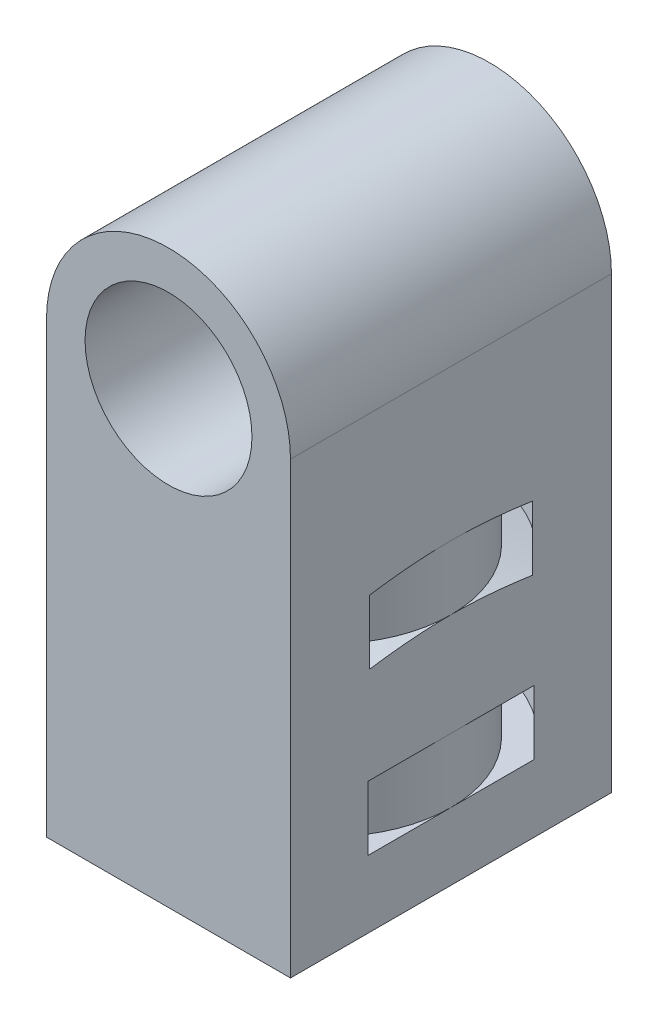
from build123d import *

# Parameters (mm, degrees)
CROQUIS1_R              = 6.5
SALIENTE_EXTRUIR1_DEPTH = 12.5
CROQUIS3_W              = 19
CROQUIS3_H              = 25
CROQUIS3_R              = 6.5
SALIENTE_EXTRUIR2_DEPTH = 25
CROQUIS8_W              = 2
CROQUIS8_H              = 5


with BuildPart() as part:
    # Croquis1 → Saliente-Extruir1 (new body, symmetric)
    with BuildSketch(Plane.XY):
        with BuildLine():
            Line((-9.5, -10), (9.5, -10))
            Line((9.5, -10), (9.5, 0))
            ThreePointArc((9.5, 0), (0, 9.5), (-9.5, 0))
            Line((-9.5, 0), (-9.5, -10))
        make_face()
        Circle(CROQUIS1_R, mode=Mode.SUBTRACT)
    extrude(amount=SALIENTE_EXTRUIR1_DEPTH, both=True)

    # Croquis3 → Saliente-Extruir2 (add)
    with BuildSketch(Plane(origin=(0, -10, 0), x_dir=(-1, 0, 0), z_dir=(0, -1, 0))):
        Rectangle(CROQUIS3_W, CROQUIS3_H)
        Circle(CROQUIS3_R, mode=Mode.SUBTRACT)
    extrude(amount=SALIENTE_EXTRUIR2_DEPTH)

    # Croquis8 → Cortar-Revolución1 (revolve, cut)
    with BuildSketch(Plane.XY):
        Polygon((-11.434596491, -17.257283371), (-11.434596491, -12.257283371), (-9.5, -11.75), (-9.5, -16.75), align=None)
        with Locations((-10.5, -27.25)):
            Rectangle(CROQUIS8_W, CROQUIS8_H)
    revolve(axis=Axis((0, -6.5, 0), (0, -1, 0)), mode=Mode.SUBTRACT)


solid = part.part
